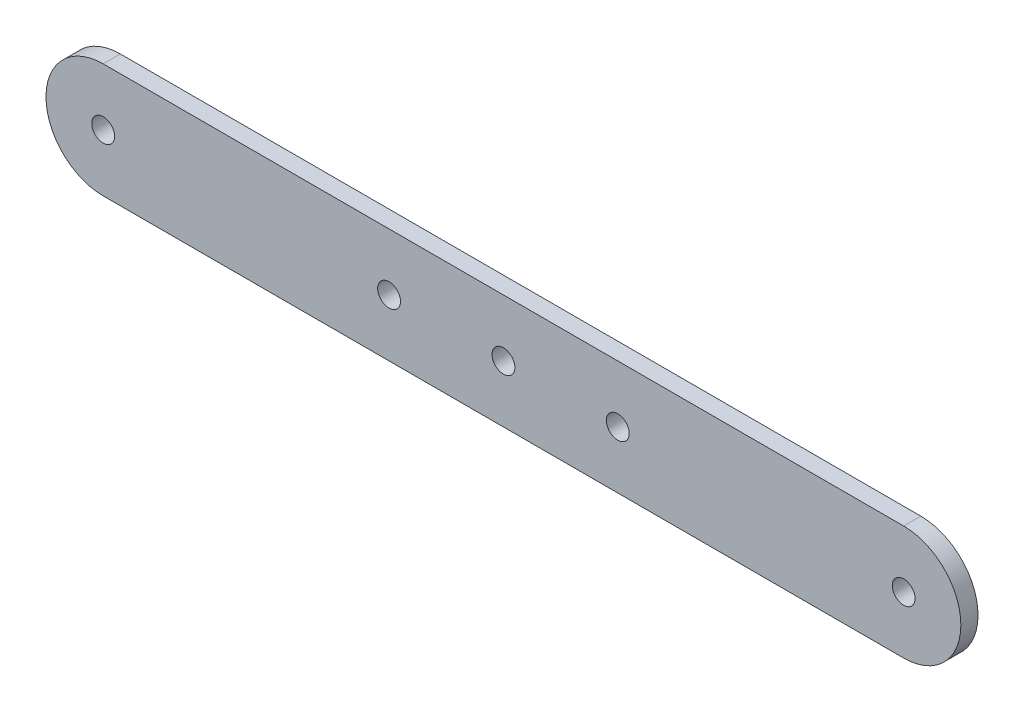
from build123d import *

# Parameters (mm, degrees)
ESQUISSE1_R        = 1
BOSS_EXTRU_2_DEPTH = 1.5


with BuildPart() as part:
    # Esquisse1 → Boss.-Extru.2 (new body)
    with BuildSketch(Plane.XY):
        with BuildLine():
            Line((-35, 5), (35, 5))
            ThreePointArc((35, 5), (40, 0), (35, -5))
            Line((35, -5), (-35, -5))
            ThreePointArc((-35, -5), (-40, 0), (-35, 5))
        make_face()
        with Locations((-35, 0)):
            Circle(ESQUISSE1_R, mode=Mode.SUBTRACT)
        Circle(ESQUISSE1_R, mode=Mode.SUBTRACT)
        with Locations((35, 0)):
            Circle(ESQUISSE1_R, mode=Mode.SUBTRACT)
        with Locations((-10, 0)):
            Circle(ESQUISSE1_R, mode=Mode.SUBTRACT)
        with Locations((10, 0)):
            Circle(ESQUISSE1_R, mode=Mode.SUBTRACT)
    extrude(amount=BOSS_EXTRU_2_DEPTH)


solid = part.part
